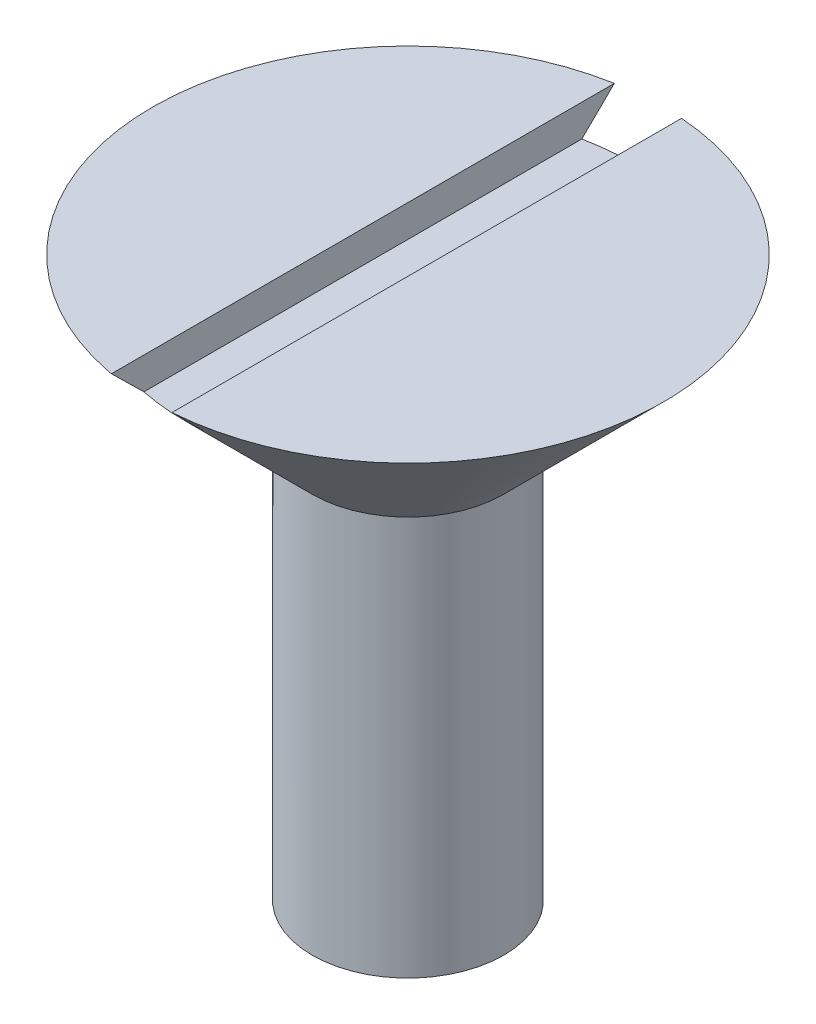
from build123d import *

# Parameters (mm, degrees)
SKETCH1_R               = 3
BOSS_EXTRUDE1_DEPTH     = 12.5
CUT_EXTRUDE4_DEPTH      = 9
CUT_EXTRUDE4_DEPTH_BACK = 9


with BuildPart() as part:
    # Sketch1 → Boss-Extrude1 (new body)
    with BuildSketch(Plane(origin=(0, 0, 0), x_dir=(1, 0, 0), z_dir=(0, 1, 0))):
        Circle(SKETCH1_R)
    extrude(amount=BOSS_EXTRUDE1_DEPTH)

    # Sketch3 → Revolve1 (revolve)
    with BuildSketch(Plane.XY):
        Polygon((-3, 12.5), (-8, 17.5), (0, 17.5), (0, 12.5), align=None)
    revolve(axis=Axis((0, 17.5, 0), (0, -1, 0)))

    # Sketch4 → Cut-Extrude4 (cut, two sides)
    with BuildSketch(Plane.XY) as cut_extrude4_sk:
        Polygon((0.588175988, 67.243680335), (0.588175988, 17.501049711), (0.588175988, 16.5), (-1.411824012, 16.5), (-1.411824012, 17.501049711), (-1.411824012, 67.243680335), (-1.411824012, 166.728941583), (0.588175988, 166.728941583), align=None)
    extrude(amount=CUT_EXTRUDE4_DEPTH, mode=Mode.SUBTRACT)
    extrude(cut_extrude4_sk.sketch, amount=-CUT_EXTRUDE4_DEPTH_BACK, mode=Mode.SUBTRACT)

    # Sketch6 → Revolve2 (revolve)
    with BuildSketch(Plane.XY):
        Polygon((3, 0), (0, -1.732050808), (0, 0), align=None)
    revolve(axis=Axis((0, -1.732050808, 0), (0, 1, 0)))


solid = part.part
